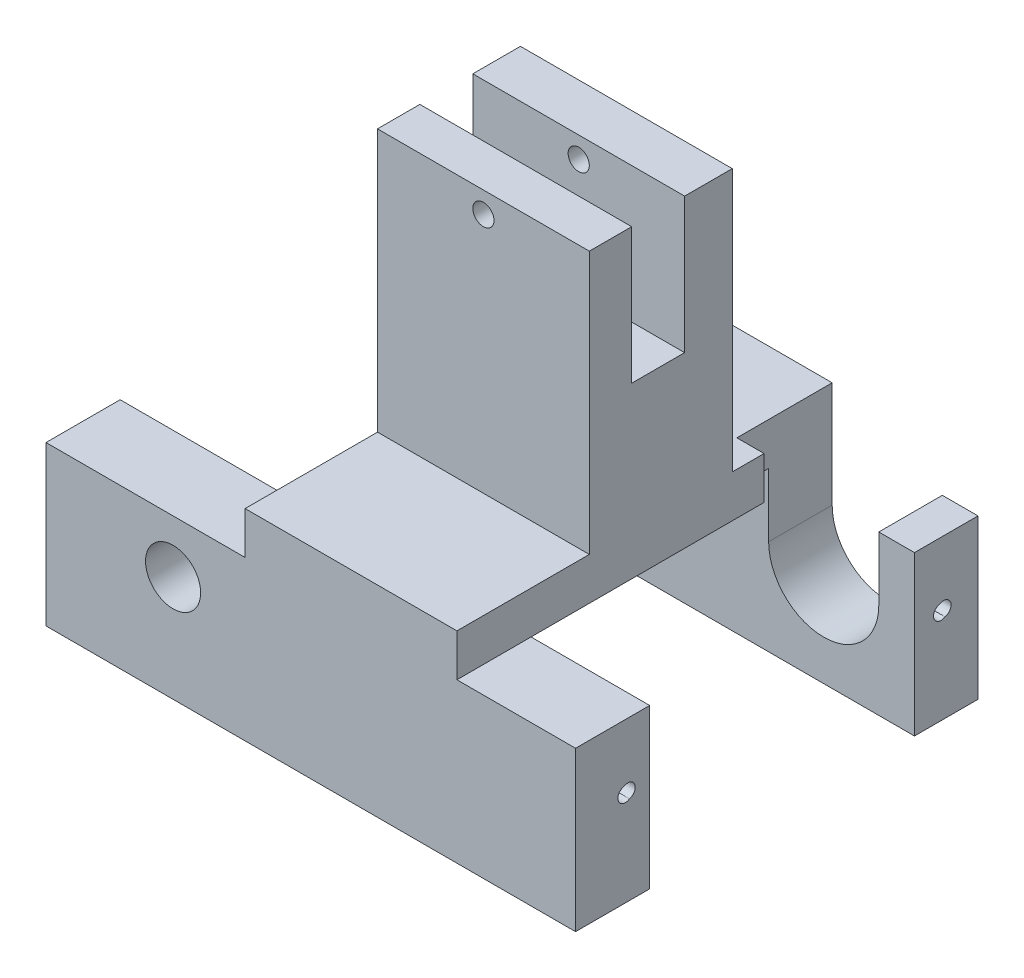
from build123d import *

# Parameters (mm, degrees)
SKETCH1_W           = 63.5
SKETCH1_H           = 48.26
BOSS_EXTRUDE1_DEPTH = 55.626
SKETCH2_W           = 31.75
SKETCH2_H           = 19.05
SKETCH2_W_2         = 15.242568483
SKETCH2_H_2         = 31.496
SKETCH2_W_3         = 6.35
SKETCH2_H_3         = 16.256
SKETCH2_W_4         = 15.875
CUT_EXTRUDE2_DEPTH  = 64.5
SKETCH3_W           = 23.876
SKETCH3_H           = 36.576
SKETCH3_W_2         = 14.224
CUT_EXTRUDE3_DEPTH  = 49.26
SKETCH4_R           = 1.27
CUT_EXTRUDE4_DEPTH  = 33.385
CUT_EXTRUDE6_REACH  = 50.26
SKETCH6_R           = 3.302
SKETCH7_R           = 3.302
CUT_EXTRUDE7_DEPTH  = 49.26
CUT_EXTRUDE11_DEPTH = 11.43
SKETCH10_R          = 0.889
CUT_EXTRUDE10_DEPTH = 6.35
SKETCH9_R           = 0.889
CUT_EXTRUDE9_DEPTH  = 6.35


with BuildPart() as part:
    # Sketch1 → Boss-Extrude1 (new body)
    with BuildSketch(Plane(origin=(0, 0, 0), x_dir=(1, 0, 0), z_dir=(0, 1, 0))):
        with Locations((31.75, 24.13)):
            Rectangle(SKETCH1_W, SKETCH1_H)
    extrude(amount=BOSS_EXTRUDE1_DEPTH)

    # Sketch2 → Cut-Extrude2 (cut, through all)
    with BuildSketch(Plane(origin=(63.5, 0, 0), x_dir=(0, 0, -1), z_dir=(1, 0, 0))):
        with Locations((24.765, 9.525)):
            Rectangle(SKETCH2_W, SKETCH2_H)
        with Locations((40.638715758, 39.878)):
            Rectangle(SKETCH2_W_2, SKETCH2_H_2)
        with Locations((24.13, 47.498)):
            Rectangle(SKETCH2_W_3, SKETCH2_H_3)
        with Locations((7.9375, 39.878)):
            Rectangle(SKETCH2_W_4, SKETCH2_H_2)
    extrude(amount=-CUT_EXTRUDE2_DEPTH, mode=Mode.SUBTRACT)

    # Sketch3 → Cut-Extrude3 (cut, through all)
    with BuildSketch(Plane.XY):
        with Locations((11.938, 37.338)):
            Rectangle(SKETCH3_W, SKETCH3_H)
        with Locations((56.388, 37.338)):
            Rectangle(SKETCH3_W_2, SKETCH3_H)
    extrude(amount=-CUT_EXTRUDE3_DEPTH, mode=Mode.SUBTRACT)

    # Sketch4 → Cut-Extrude4 (cut, through all)
    with BuildSketch(Plane.XY.offset(-15.875)):
        with Locations((36.576, 53.086)):
            Circle(SKETCH4_R)
    extrude(amount=-CUT_EXTRUDE4_DEPTH, mode=Mode.SUBTRACT)

    # Sketch6 → Cut-Extrude6 (cut, up to next)
    with BuildSketch(Plane(origin=(0, 0, -48.26), x_dir=(-1, 0, 0), z_dir=(0, 0, -1)), mode=Mode.PRIVATE) as cut_extrude6_sk1:
        with Locations((-15.24, 12.7)):
            Circle(SKETCH6_R)
    cut_extrude6_tool1 = extrude(cut_extrude6_sk1.sketch, amount=-CUT_EXTRUDE6_REACH, mode=Mode.PRIVATE) & part.part
    add(cut_extrude6_tool1.solids().sort_by_distance((15.24, 12.7, -48.26))[0], mode=Mode.SUBTRACT)

    # Sketch7 → Cut-Extrude7 (cut, through all)
    with BuildSketch(Plane(origin=(0, 0, -48.26), x_dir=(-1, 0, 0), z_dir=(0, 0, -1))):
        with Locations((-15.24, 12.7)):
            Circle(SKETCH7_R)
    extrude(amount=-CUT_EXTRUDE7_DEPTH, mode=Mode.SUBTRACT)

    # Sketch8 → Cut-Extrude11 (cut)
    with BuildSketch(Plane(origin=(0, 0, -48.26), x_dir=(-1, 0, 0), z_dir=(0, 0, -1))):
        with BuildLine():
            Line((-49.276, 24.13), (-46.013321356, 24.13))
            Line((-46.013321356, 24.13), (-46.013321356, 11.43))
            ThreePointArc((-46.013321356, 11.43), (-52.617321356, 4.826), (-59.221321356, 11.43))
            Line((-59.221321356, 11.43), (-59.221321356, 19.05))
            Line((-59.221321356, 19.05), (-49.276, 19.05))
            Line((-49.276, 19.05), (-49.276, 24.13))
        make_face()
    extrude(amount=-CUT_EXTRUDE11_DEPTH, mode=Mode.SUBTRACT)

    # Sketch10 → Cut-Extrude10 (cut)
    with BuildSketch(Plane(origin=(63.5, 0, 0), x_dir=(0, 0, -1), z_dir=(1, 0, 0))):
        with Locations((6.26745, 11.43)):
            Circle(SKETCH10_R)
        with Locations((44.13885, 11.43)):
            Circle(SKETCH10_R)
    extrude(amount=-CUT_EXTRUDE10_DEPTH, mode=Mode.SUBTRACT)

    # Sketch9 → Cut-Extrude9 (cut)
    with BuildSketch(Plane(origin=(63.5, 0, 0), x_dir=(0, 0, -1), z_dir=(1, 0, 0))):
        with Locations((5.969, 11.303)):
            Circle(SKETCH9_R)
        with Locations((43.815, 11.303)):
            Circle(SKETCH9_R)
    extrude(amount=-CUT_EXTRUDE9_DEPTH, mode=Mode.SUBTRACT)


solid = part.part
